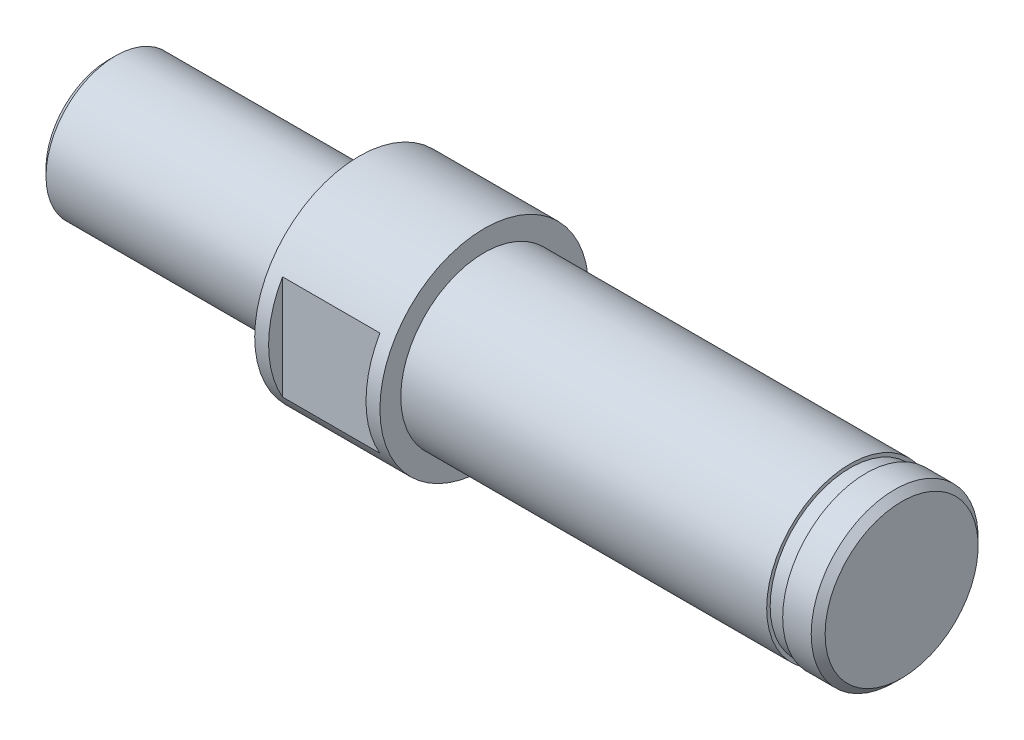
from build123d import *

# Parameters (mm, degrees)
SKETCH3_W           = 1.15
SKETCH3_H           = 0.25
SKETCH2_OUTSIDE_W   = 29.164
SKETCH2_OUTSIDE_H   = 29.164
SKETCH2_OUTSIDE_W_2 = 13
SKETCH2_OUTSIDE_H_2 = 15
CUT_EXTRUDE1_DEPTH  = 7
CHAMFER1_SIZE       = 0.5


with BuildPart() as part:
    # Sketch1 → Revolve1 (revolve)
    with BuildSketch(Plane.XY):
        Polygon((-18, 0), (-18, 5), (0, 5), (0, 7.5), (9, 7.5), (9, 6), (39, 6), (39, 0), align=None)
    revolve(axis=Axis((-21.980615115, 0, 0), (1, 0, 0)))

    # Sketch3 → Cut-Revolve1 (revolve, cut)
    with BuildSketch(Plane.XY):
        with Locations((35.875, 5.875)):
            Rectangle(SKETCH3_W, SKETCH3_H)
    revolve(axis=Axis((-19.403846942, 0, 0), (1, 0, 0)), mode=Mode.SUBTRACT)

    # Sketch2 outside → Cut-Extrude1 (cut)
    with BuildSketch(Plane(origin=(1, 0, 0), x_dir=(0, 0, -1), z_dir=(1, 0, 0))):
        Rectangle(SKETCH2_OUTSIDE_W, SKETCH2_OUTSIDE_H)
        Rectangle(SKETCH2_OUTSIDE_W_2, SKETCH2_OUTSIDE_H_2, mode=Mode.SUBTRACT)
    extrude(amount=CUT_EXTRUDE1_DEPTH, mode=Mode.SUBTRACT)

    # Chamfer1
    chamfer1_edges = [part.edges().sort_by_distance(p)[0] for p in [
        (39, -6, 0),
        (-18, -5, 0),
    ]]
    chamfer(chamfer1_edges, length=CHAMFER1_SIZE)


solid = part.part
